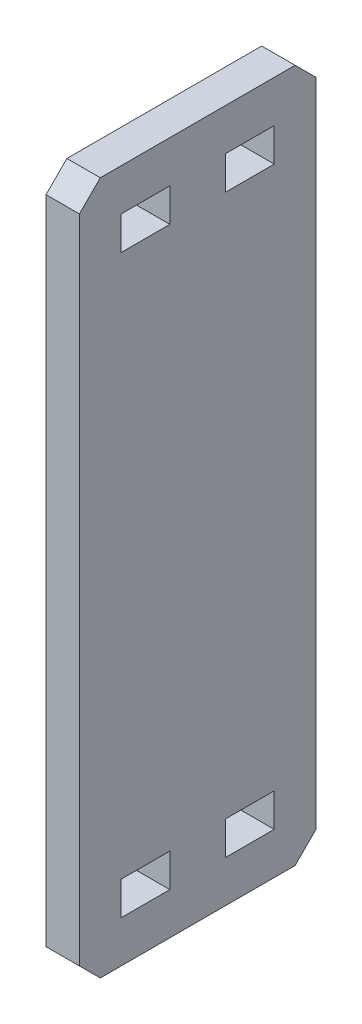
from build123d import *

# Parameters (mm, degrees)
SKETCH1_W           = 43.18
SKETCH1_H           = 126.492
SKETCH1_W_2         = 8.89
SKETCH1_H_2         = 6.096
BOSS_EXTRUDE1_DEPTH = 3.048
CHAMFER1_SIZE       = 3.81


with BuildPart() as part:
    # Sketch1 → Boss-Extrude1 (new, symmetric)
    with BuildSketch(Plane(origin=(0, 0, 0), x_dir=(0, 0, -1), z_dir=(1, 0, 0))):
        with Locations((-111.027292876, 0)):
            Rectangle(SKETCH1_W, SKETCH1_H)
        with Locations((-101.502292876, 52.578)):
            Rectangle(SKETCH1_W_2, SKETCH1_H_2, mode=Mode.SUBTRACT)
        with Locations((-120.552292876, 52.578)):
            Rectangle(SKETCH1_W_2, SKETCH1_H_2, mode=Mode.SUBTRACT)
        with Locations((-101.502292876, -52.578)):
            Rectangle(SKETCH1_W_2, SKETCH1_H_2, mode=Mode.SUBTRACT)
        with Locations((-120.552292876, -52.578)):
            Rectangle(SKETCH1_W_2, SKETCH1_H_2, mode=Mode.SUBTRACT)
    extrude(amount=BOSS_EXTRUDE1_DEPTH, both=True)

    # Chamfer1
    chamfer1_edges = [part.edges().sort_by_distance(p)[0] for p in [
        (0, -63.246, 89.437292876),
        (0, -63.246, 132.617292876),
        (0, 63.246, 89.437292876),
        (0, 63.246, 132.617292876),
    ]]
    chamfer(chamfer1_edges, length=CHAMFER1_SIZE)


solid = part.part
